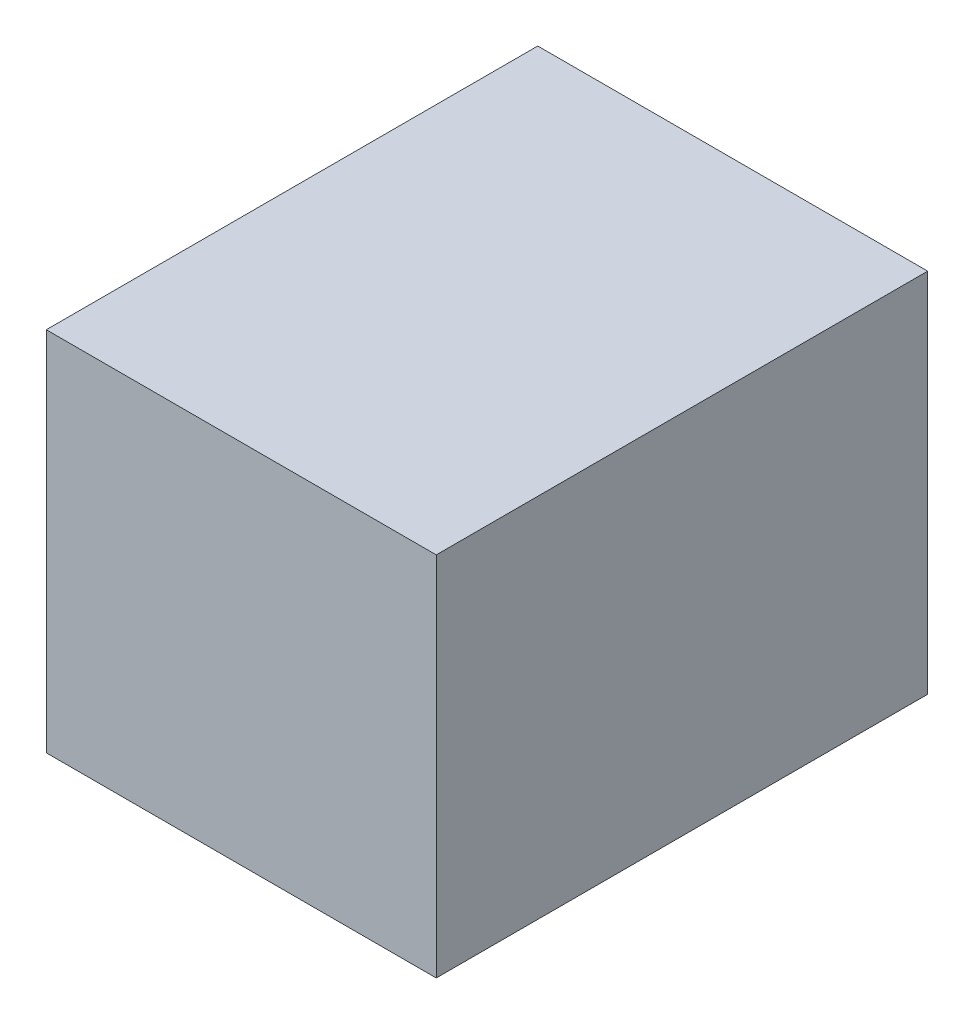
from build123d import *

# Parameters (mm, degrees)
SKETCH1_W           = 36.5
SKETCH1_H           = 46
BOSS_EXTRUDE1_DEPTH = 34.3


with BuildPart() as part:
    # Sketch1 → Boss-Extrude1 (new body)
    with BuildSketch(Plane(origin=(0, 0, 0), x_dir=(1, 0, 0), z_dir=(0, 1, 0))):
        Rectangle(SKETCH1_W, SKETCH1_H)
    extrude(amount=BOSS_EXTRUDE1_DEPTH)


solid = part.part
